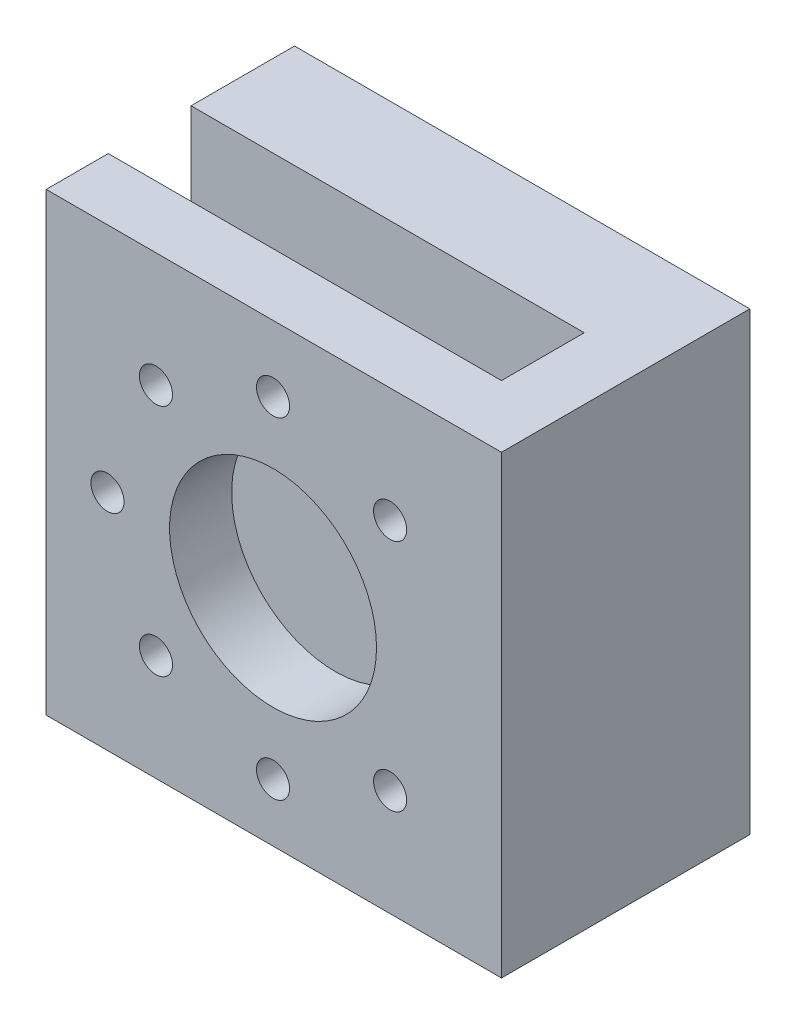
from build123d import *

# Parameters (mm, degrees)
RESSALTO_EXTRUS_O2_DEPTH = 25
ESBO_O5_R                = 4
CORTE_EXTRUS_O3_DEPTH    = 85
ESBO_O6_R                = 7
CORTE_EXTRUS_O4_DEPTH    = 20
ESBO_O12_W               = 15
ESBO_O12_H               = 110
RESSALTO_EXTRUS_O3_DEPTH = 20
ESBO_O13_W               = 110
ESBO_O13_H               = 110
RESSALTO_EXTRUS_O4_DEPTH = 15
ESBO_O14_R               = 25
ESBO_O14_R_2             = 4
CORTE_EXTRUS_O5_DEPTH    = 15


with BuildPart() as part:
    # Esboço1 → Ressalto-extrusão2 (new body)
    with BuildSketch(Plane.XY):
        with BuildLine():
            Line((6.820228442, 22.38699838), (6.820228442, 18.727313079))
            ThreePointArc((6.820228442, 18.727313079), (19.00741694, -1.705466141), (1.689928033, -18.018976127))
            Line((1.689928033, -18.018976127), (1.689928033, -54.024230705))
            Line((1.689928033, -54.024230705), (55.189928033, -54.024230705))
            Line((55.189928033, -54.024230705), (55.189928033, 55.975769295))
            Line((55.189928033, 55.975769295), (1.689928033, 55.975769295))
            Line((1.689928033, 55.975769295), (-1.310071967, 55.975769295))
            Line((-1.310071967, 55.975769295), (-54.810071967, 55.975769295))
            Line((-54.810071967, 55.975769295), (-54.810071967, -54.024230705))
            Line((-54.810071967, -54.024230705), (-1.310071967, -54.024230705))
            Line((-1.310071967, -54.024230705), (-1.310071967, -18.018976127))
            ThreePointArc((-1.310071967, -18.018976127), (-18.627560875, -1.705466141), (-6.440372377, 18.727313079))
            Line((-6.440372377, 18.727313079), (-6.440372377, 22.38699838))
            Line((-6.440372377, 22.38699838), (6.180238055, 22.38699838))
            Line((6.180238055, 22.38699838), (6.820228442, 22.38699838))
        make_face()
    extrude(amount=RESSALTO_EXTRUS_O2_DEPTH)

    # Esboço5 → Corte-extrusão3 (cut)
    with BuildSketch(Plane.ZY.offset(54.810071967)):
        with Locations((12.5, -41.024230705)):
            Circle(ESBO_O5_R)
    extrude(amount=-CORTE_EXTRUS_O3_DEPTH, mode=Mode.SUBTRACT)

    # Esboço6 → Corte-extrusão4 (cut)
    with BuildSketch(Plane.ZY.offset(54.810071967)):
        with Locations((12.5, -41.024230705)):
            Circle(ESBO_O6_R)
    extrude(amount=-CORTE_EXTRUS_O4_DEPTH, mode=Mode.SUBTRACT)

    # Esboço12 → Ressalto-extrusão3 (add)
    with BuildSketch(Plane.XY.offset(25)):
        with Locations((47.689928033, 0.975769295)):
            Rectangle(ESBO_O12_W, ESBO_O12_H)
    extrude(amount=RESSALTO_EXTRUS_O3_DEPTH)

    # Esboço13 → Ressalto-extrusão4 (add)
    with BuildSketch(Plane.XY.offset(45)):
        with Locations((0.189928033, 0.975769295)):
            Rectangle(ESBO_O13_W, ESBO_O13_H)
    extrude(amount=RESSALTO_EXTRUS_O4_DEPTH)

    # Esboço14 → Corte-extrusão5 (cut)
    with BuildSketch(Plane.XY.offset(60)):
        Circle(ESBO_O14_R)
        with Locations((0, 40)):
            Circle(ESBO_O14_R_2)
        with Locations((-40, 0)):
            Circle(ESBO_O14_R_2)
        with Locations((0, -40)):
            Circle(ESBO_O14_R_2)
        with Locations((-28.284271247, 28.284271247)):
            Circle(ESBO_O14_R_2)
        with Locations((28.284271247, 28.284271247)):
            Circle(ESBO_O14_R_2)
        with Locations((28.284271247, -28.284271247)):
            Circle(ESBO_O14_R_2)
        with Locations((-28.284271247, -28.284271247)):
            Circle(ESBO_O14_R_2)
    extrude(amount=-CORTE_EXTRUS_O5_DEPTH, mode=Mode.SUBTRACT)


solid = part.part
